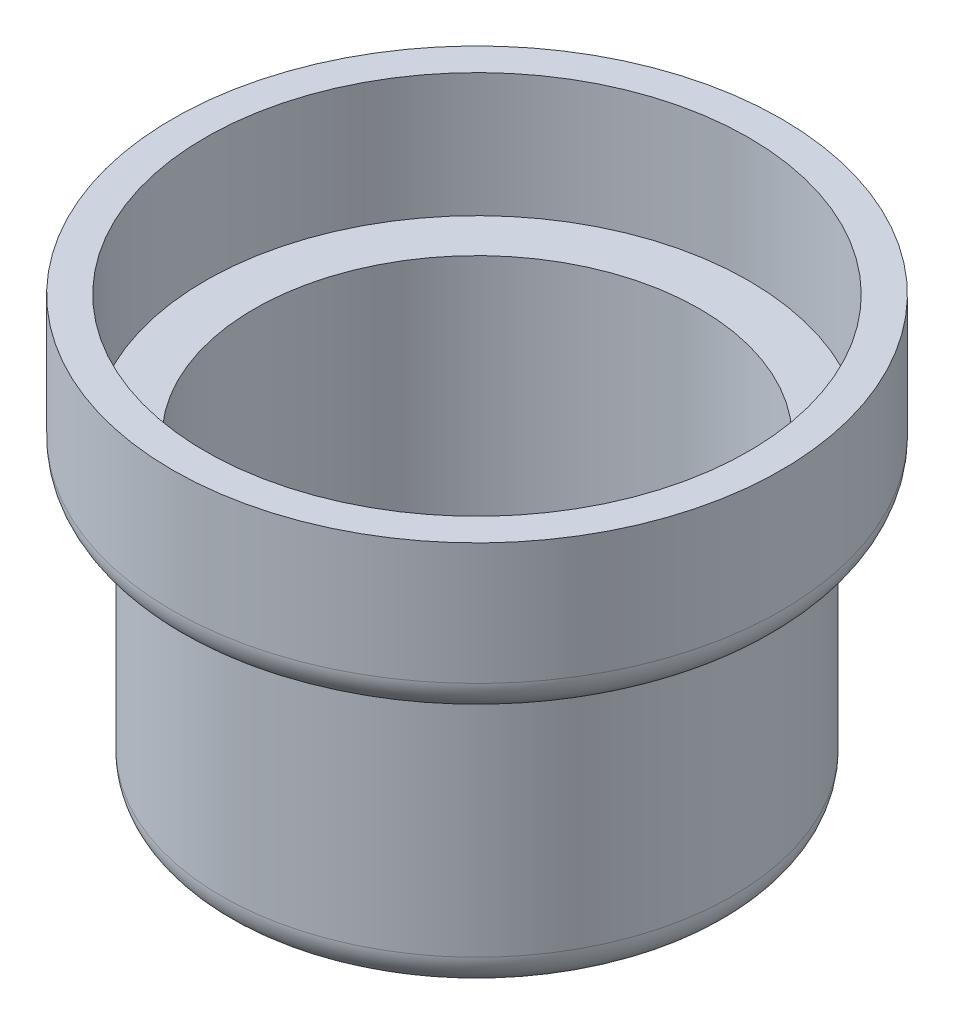
from build123d import *

# Parameters (mm, degrees)
FILLET1_R = 2.54


with BuildPart() as part:
    # Sketch2 → Revolve1 (revolve)
    with BuildSketch(Plane.XY):
        Polygon((0, 0), (18.653125, 0), (18.653125, 19.84375), (22.225, 19.84375), (22.225, 31.27375), (19.84375, 31.27375), (19.84375, 22.225), (16.271875, 22.225), (16.271875, 2.38125), (0, 2.38125), align=None)
    revolve(axis=Axis((0, 0, 0), (0, 1, 0)))

    # Fillet1
    fillet1_edges = [part.edges().sort_by_distance(p)[0] for p in [
        (-18.653125, 0, 0),
        (-22.225, 19.84375, 0),
    ]]
    fillet(fillet1_edges, radius=FILLET1_R)


solid = part.part
